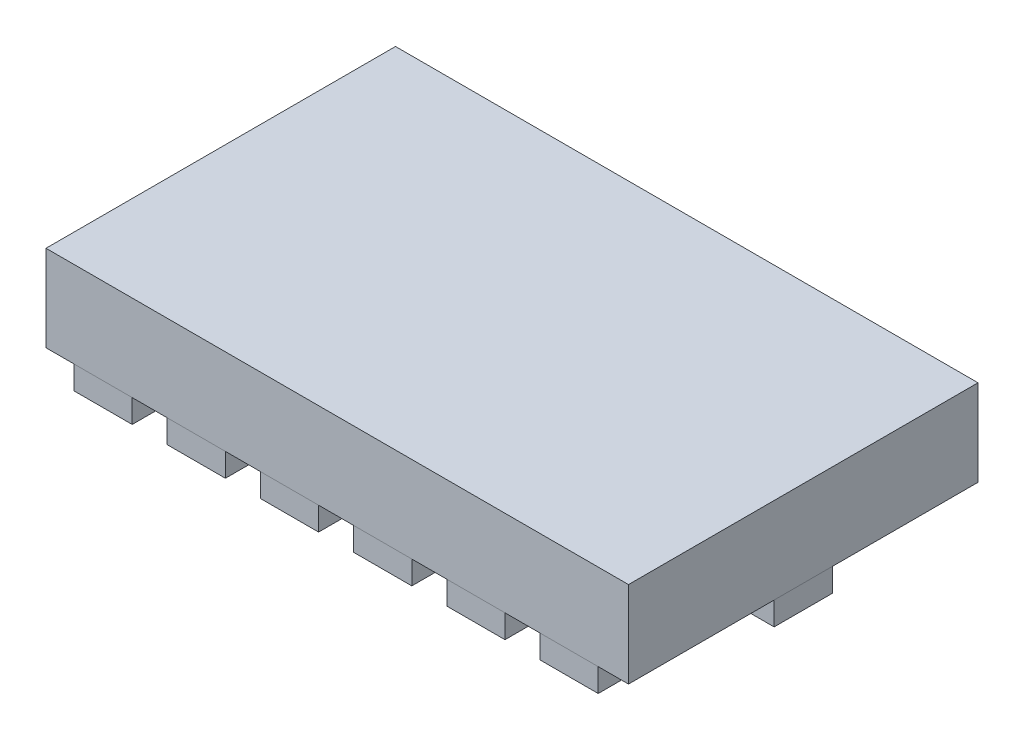
from build123d import *

# Parameters (mm, degrees)
SKETCH1_W              = 5
SKETCH1_H              = 3
BOSS_EXTRUDE1_DEPTH    = 0.74
SKETCH2_W              = 0.813
SKETCH2_H              = 0.5
BOSS_EXTRUDE2_DEPTH    = 0.2
BOSS_EXTRUDE2_2_DEPTH  = 0.2
SKETCH2_W_2            = 0.5
SKETCH2_H_2            = 0.813
BOSS_EXTRUDE2_3_DEPTH  = 0.2
BOSS_EXTRUDE2_4_DEPTH  = 0.2
BOSS_EXTRUDE2_5_DEPTH  = 0.2
BOSS_EXTRUDE2_6_DEPTH  = 0.2
BOSS_EXTRUDE2_7_DEPTH  = 0.2
BOSS_EXTRUDE2_8_DEPTH  = 0.2
BOSS_EXTRUDE2_9_DEPTH  = 0.2
BOSS_EXTRUDE2_10_DEPTH = 0.2
BOSS_EXTRUDE2_11_DEPTH = 0.2
BOSS_EXTRUDE2_12_DEPTH = 0.2
BOSS_EXTRUDE2_13_DEPTH = 0.2
BOSS_EXTRUDE2_14_DEPTH = 0.2


with BuildPart() as part:
    # Sketch1 → Boss-Extrude1 (new body)
    with BuildSketch(Plane(origin=(0, 0, 0), x_dir=(1, 0, 0), z_dir=(0, 1, 0))):
        Rectangle(SKETCH1_W, SKETCH1_H)
    extrude(amount=BOSS_EXTRUDE1_DEPTH)


with BuildPart() as body_2:
    # Sketch2 → Boss-Extrude2 (new body)
    with BuildSketch(Plane.XZ):
        with Locations((2.0935, 0)):
            Rectangle(SKETCH2_W, SKETCH2_H)
    extrude(amount=BOSS_EXTRUDE2_DEPTH)


with BuildPart() as body_3:
    # Sketch2 → Boss-Extrude2 2 (new body)
    with BuildSketch(Plane.XZ):
        with Locations((-2.0935, 0)):
            Rectangle(SKETCH2_W, SKETCH2_H)
    extrude(amount=BOSS_EXTRUDE2_2_DEPTH)


with BuildPart() as body_4:
    # Sketch2 → Boss-Extrude2 3 (new body)
    with BuildSketch(Plane.XZ):
        with Locations((-2.01, 1.0935)):
            Rectangle(SKETCH2_W_2, SKETCH2_H_2)
    extrude(amount=BOSS_EXTRUDE2_3_DEPTH)


with BuildPart() as body_5:
    # Sketch2 → Boss-Extrude2 4 (new body)
    with BuildSketch(Plane.XZ):
        with Locations((-1.21, 1.0935)):
            Rectangle(SKETCH2_W_2, SKETCH2_H_2)
    extrude(amount=BOSS_EXTRUDE2_4_DEPTH)


with BuildPart() as body_6:
    # Sketch2 → Boss-Extrude2 5 (new body)
    with BuildSketch(Plane.XZ):
        with Locations((-0.41, 1.0935)):
            Rectangle(SKETCH2_W_2, SKETCH2_H_2)
    extrude(amount=BOSS_EXTRUDE2_5_DEPTH)


with BuildPart() as body_7:
    # Sketch2 → Boss-Extrude2 6 (new body)
    with BuildSketch(Plane.XZ):
        with Locations((0.39, 1.0935)):
            Rectangle(SKETCH2_W_2, SKETCH2_H_2)
    extrude(amount=BOSS_EXTRUDE2_6_DEPTH)


with BuildPart() as body_8:
    # Sketch2 → Boss-Extrude2 7 (new body)
    with BuildSketch(Plane.XZ):
        with Locations((1.19, 1.0935)):
            Rectangle(SKETCH2_W_2, SKETCH2_H_2)
    extrude(amount=BOSS_EXTRUDE2_7_DEPTH)


with BuildPart() as body_9:
    # Sketch2 → Boss-Extrude2 8 (new body)
    with BuildSketch(Plane.XZ):
        with Locations((1.99, 1.0935)):
            Rectangle(SKETCH2_W_2, SKETCH2_H_2)
    extrude(amount=BOSS_EXTRUDE2_8_DEPTH)


with BuildPart() as body_10:
    # Sketch2 → Boss-Extrude2 9 (new body)
    with BuildSketch(Plane.XZ):
        with Locations((1.99, -1.0935)):
            Rectangle(SKETCH2_W_2, SKETCH2_H_2)
    extrude(amount=BOSS_EXTRUDE2_9_DEPTH)


with BuildPart() as body_11:
    # Sketch2 → Boss-Extrude2 10 (new body)
    with BuildSketch(Plane.XZ):
        with Locations((1.19, -1.0935)):
            Rectangle(SKETCH2_W_2, SKETCH2_H_2)
    extrude(amount=BOSS_EXTRUDE2_10_DEPTH)


with BuildPart() as body_12:
    # Sketch2 → Boss-Extrude2 11 (new body)
    with BuildSketch(Plane.XZ):
        with Locations((0.39, -1.0935)):
            Rectangle(SKETCH2_W_2, SKETCH2_H_2)
    extrude(amount=BOSS_EXTRUDE2_11_DEPTH)


with BuildPart() as body_13:
    # Sketch2 → Boss-Extrude2 12 (new body)
    with BuildSketch(Plane.XZ):
        with Locations((-0.41, -1.0935)):
            Rectangle(SKETCH2_W_2, SKETCH2_H_2)
    extrude(amount=BOSS_EXTRUDE2_12_DEPTH)


with BuildPart() as body_14:
    # Sketch2 → Boss-Extrude2 13 (new body)
    with BuildSketch(Plane.XZ):
        with Locations((-1.21, -1.0935)):
            Rectangle(SKETCH2_W_2, SKETCH2_H_2)
    extrude(amount=BOSS_EXTRUDE2_13_DEPTH)


with BuildPart() as body_15:
    # Sketch2 → Boss-Extrude2 14 (new body)
    with BuildSketch(Plane.XZ):
        with Locations((-2.01, -1.0935)):
            Rectangle(SKETCH2_W_2, SKETCH2_H_2)
    extrude(amount=BOSS_EXTRUDE2_14_DEPTH)


solid = Compound([part.part, body_2.part, body_3.part, body_4.part, body_5.part, body_6.part, body_7.part, body_8.part, body_9.part, body_10.part, body_11.part, body_12.part, body_13.part, body_14.part, body_15.part])
